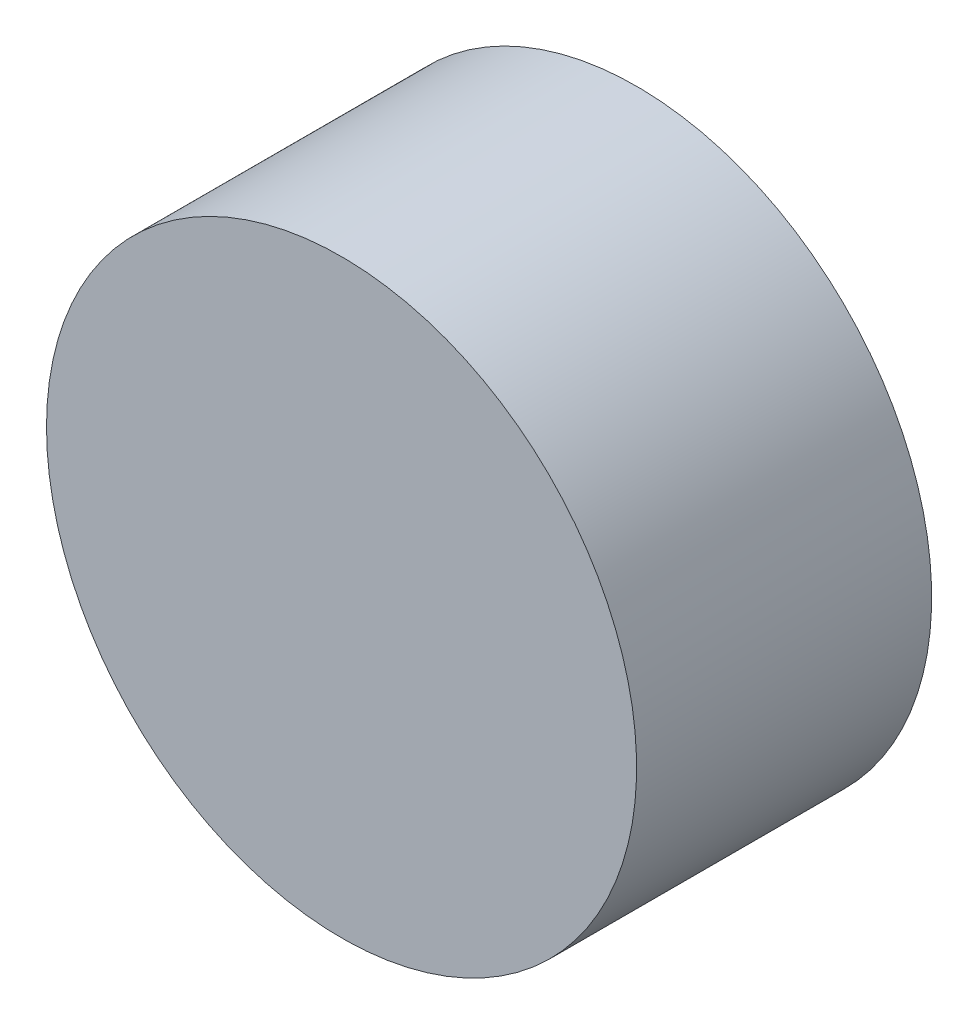
from build123d import *


with BuildPart() as part:
    # Sketch3 → Revolve1 (revolve)
    with BuildSketch(Plane(origin=(0, 0, 0), x_dir=(-1, 0, 0), z_dir=(0, -1, 0))):
        Polygon((25.4, -25.4), (25.4, 0), (28.575, 0), (28.575, -25.4), (28.575, -28.575), (0, -28.575), (0, -25.4), align=None)
    revolve(axis=Axis((0, 0, 0), (0, 0, 1)))


solid = part.part
